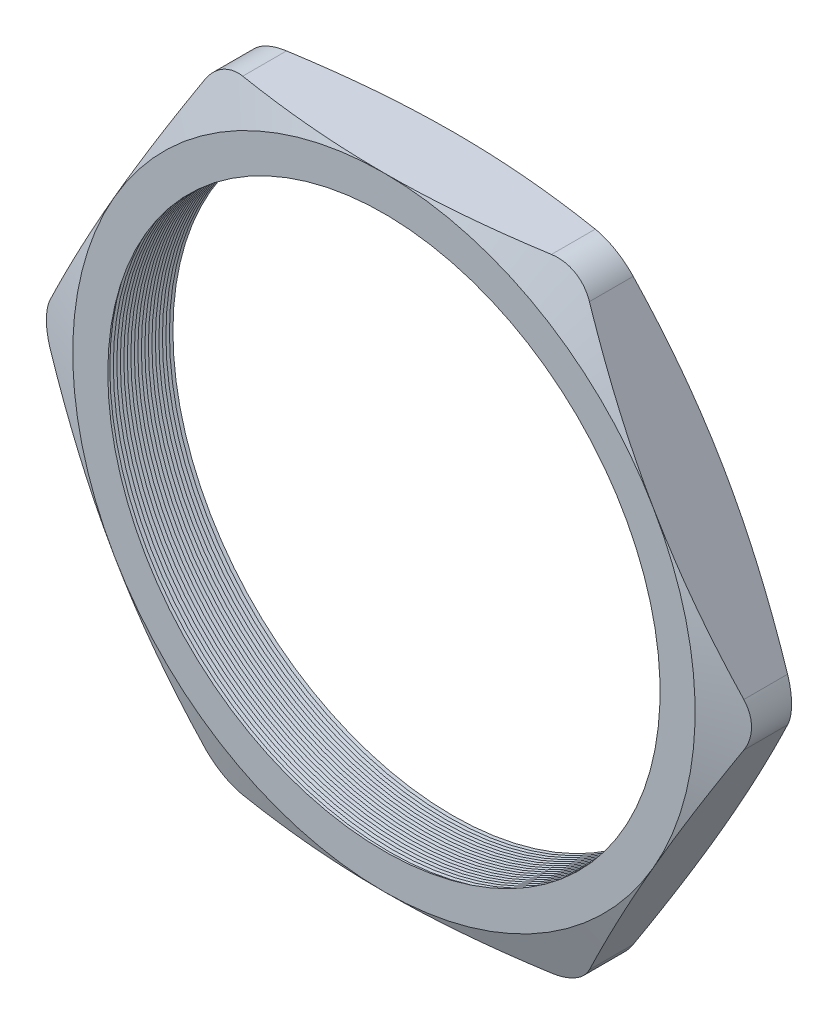
from build123d import *

# Parameters (mm, degrees)
SKETCH1_R          = 16.002
EXTRUDE1_DEPTH     = 4.064
FILLET1_R          = 2.54
SKETCH2_OUTSIDE_W  = 81.62
SKETCH2_OUTSIDE_H  = 76.826
SKETCH2_OUTSIDE_R  = 18.034
CUT_EXTRUDE1_DEPTH = 5.064
CUT_EXTRUDE1_DRAFT = -70
SKETCH3_OUTSIDE_W  = 81.62
SKETCH3_OUTSIDE_H  = 76.826
SKETCH3_OUTSIDE_R  = 18.034
CUT_EXTRUDE2_DEPTH = 5.0640001
CUT_EXTRUDE2_DRAFT = -70
LPATTERN1_COUNT    = 20
LPATTERN1_PITCH    = 0.2032


with BuildPart() as part:
    # Sketch1 → Extrude1 (new body)
    with BuildSketch(Plane.XY):
        Polygon((-20.823869509, 0), (-10.411934755, -18.034), (10.411934755, -18.034), (20.823869509, 0), (10.411934755, 18.034), (-10.411934755, 18.034), align=None)
        Circle(SKETCH1_R, mode=Mode.SUBTRACT)
    extrude(amount=EXTRUDE1_DEPTH)

    # Fillet1
    fillet1_edges = [part.edges().sort_by_distance(p)[0] for p in [
        (20.823869509, 0, 2.032),
        (10.411934755, -18.034, 2.032),
        (-10.411934755, -18.034, 2.032),
        (-20.823869509, 0, 2.032),
        (-10.411934755, 18.034, 2.032),
        (10.411934755, 18.034, 2.032),
    ]]
    fillet(fillet1_edges, radius=FILLET1_R)


with BuildPart() as cut_extrude1_tool:
    # Sketch2 outside → Cut-Extrude1 (with draft: the straight prism first)
    with BuildSketch(Plane.XY.offset(4.064)):
        Rectangle(SKETCH2_OUTSIDE_W, SKETCH2_OUTSIDE_H)
        Circle(SKETCH2_OUTSIDE_R, mode=Mode.SUBTRACT)
    extrude(amount=-CUT_EXTRUDE1_DEPTH)
    # Cut-Extrude1: the draft: its side faces are tilted about the plane it starts from
    cut_extrude1_sides = [cut_extrude1_tool.faces().sort_by_distance(p)[0] for p in [
        (0, -38.413, 1.532),
        (40.81, 0, 1.532),
        (0, 38.413, 1.532),
        (-40.81, 0, 1.532),
        (-18.034, 0, 1.532),
    ]]
    draft(cut_extrude1_sides, Plane.XY.offset(4.064), CUT_EXTRUDE1_DRAFT)


with BuildPart() as part_1:
    add(part.part)

    # Cut-Extrude1: cut by cut_extrude1_tool
    add(cut_extrude1_tool.part, mode=Mode.SUBTRACT)


with BuildPart() as cut_extrude2_tool:
    # Sketch3 outside → Cut-Extrude2 (with draft: the straight prism first)
    with BuildSketch(Plane(origin=(0, 0, 0), x_dir=(-1, 0, 0), z_dir=(0, 0, -1))):
        Rectangle(SKETCH3_OUTSIDE_W, SKETCH3_OUTSIDE_H)
        Circle(SKETCH3_OUTSIDE_R, mode=Mode.SUBTRACT)
    extrude(amount=-CUT_EXTRUDE2_DEPTH)
    # Cut-Extrude2: the draft: its side faces are tilted about the plane it starts from
    cut_extrude2_sides = [cut_extrude2_tool.faces().sort_by_distance(p)[0] for p in [
        (0, -38.413, 2.53200005),
        (-40.81, 0, 2.53200005),
        (0, 38.413, 2.53200005),
        (40.81, 0, 2.53200005),
        (18.034, 0, 2.53200005),
    ]]
    draft(cut_extrude2_sides, Plane(origin=(0, 0, 0), x_dir=(-1, 0, 0), z_dir=(0, 0, -1)), CUT_EXTRUDE2_DRAFT)


with BuildPart() as part_2:
    add(part_1.part)

    # Cut-Extrude2: cut by cut_extrude2_tool
    add(cut_extrude2_tool.part, mode=Mode.SUBTRACT)

    # Sketch4 → Cut-Revolve1 (revolve, cut)
    with BuildSketch(Plane(origin=(0, 0, 0), x_dir=(1, 0, 0), z_dir=(0, 1, 0))):
        Polygon((-16.002, -4.064), (-16.002, -3.624059095), (-16.383, -3.844029547), align=None)
    cut_revolve1 = revolve(axis=Axis((0, 0, 4.064), (0, 0, -1)), mode=Mode.SUBTRACT)

    # LPattern1: Cut-Revolve1 ×20
    with Locations(*[(0, 0, -i * LPATTERN1_PITCH) for i in range(1, LPATTERN1_COUNT)]):
        add(cut_revolve1, mode=Mode.SUBTRACT)


solid = part_2.part
